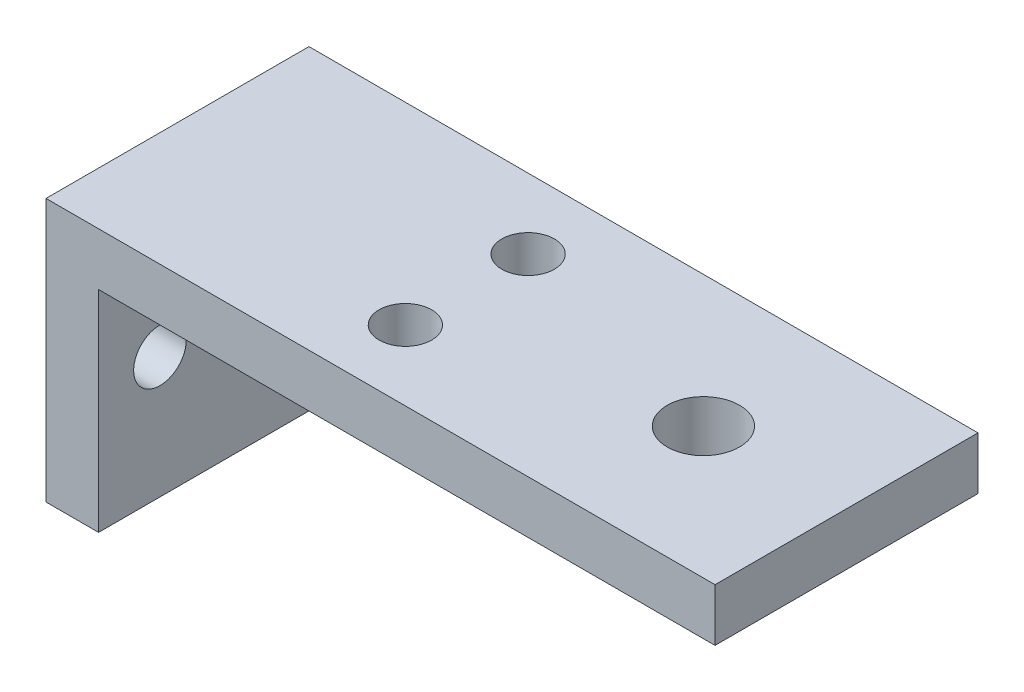
from build123d import *

# Parameters (mm, degrees)
CROQUIS1_W              = 3
CROQUIS1_H              = 12
CROQUIS1_H_2            = 3
CROQUIS1_W_2            = 47
SALIENTE_EXTRUIR1_DEPTH = 15
CROQUIS2_R              = 1.5
CORTAR_EXTRUIR1_DEPTH   = 30
CROQUIS4_R              = 2.063665481
CORTAR_EXTRUIR3_DEPTH   = 10
CROQUIS5_W              = 11.835753584
CROQUIS5_H              = 15
CORTAR_EXTRUIR4_DEPTH   = 30
CROQUIS6_R              = 1.5
CORTAR_EXTRUIR5_DEPTH   = 10


with BuildPart() as part:
    # Croquis1 → Saliente-Extruir1 (new body)
    with BuildSketch(Plane.XY):
        with Locations((0, -1.5)):
            Rectangle(CROQUIS1_W, CROQUIS1_H)
        with Locations((0, 6)):
            Rectangle(CROQUIS1_W, CROQUIS1_H_2)
        with Locations((25, 6)):
            Rectangle(CROQUIS1_W_2, CROQUIS1_H_2)
    extrude(amount=SALIENTE_EXTRUIR1_DEPTH)

    # Croquis2 → Cortar-Extruir1 (cut)
    with BuildSketch(Plane(origin=(1.5, 0, 0), x_dir=(0, 0, -1), z_dir=(1, 0, 0))):
        with Locations((-11.5, -0.5)):
            Circle(CROQUIS2_R)
        with Locations((-4, -0.5)):
            Circle(CROQUIS2_R)
    extrude(amount=-CORTAR_EXTRUIR1_DEPTH, mode=Mode.SUBTRACT)

    # Croquis4 → Cortar-Extruir3 (cut)
    with BuildSketch(Plane(origin=(0, 7.5, 0), x_dir=(1, 0, 0), z_dir=(0, 1, 0))):
        with Locations((28.5, -7.5)):
            Circle(CROQUIS4_R)
    extrude(amount=-CORTAR_EXTRUIR3_DEPTH, mode=Mode.SUBTRACT)

    # Croquis5 → Cortar-Extruir4 (cut)
    with BuildSketch(Plane(origin=(0, 7.5, 0), x_dir=(1, 0, 0), z_dir=(0, 1, 0))):
        with Locations((42.582123208, -7.5)):
            Rectangle(CROQUIS5_W, CROQUIS5_H)
    extrude(amount=-CORTAR_EXTRUIR4_DEPTH, mode=Mode.SUBTRACT)

    # Croquis6 → Cortar-Extruir5 (cut)
    with BuildSketch(Plane(origin=(0, 7.5, 0), x_dir=(1, 0, 0), z_dir=(0, 1, 0))):
        with Locations((15, -4)):
            Circle(CROQUIS6_R)
        with Locations((15, -11)):
            Circle(CROQUIS6_R)
    extrude(amount=-CORTAR_EXTRUIR5_DEPTH, mode=Mode.SUBTRACT)


solid = part.part
